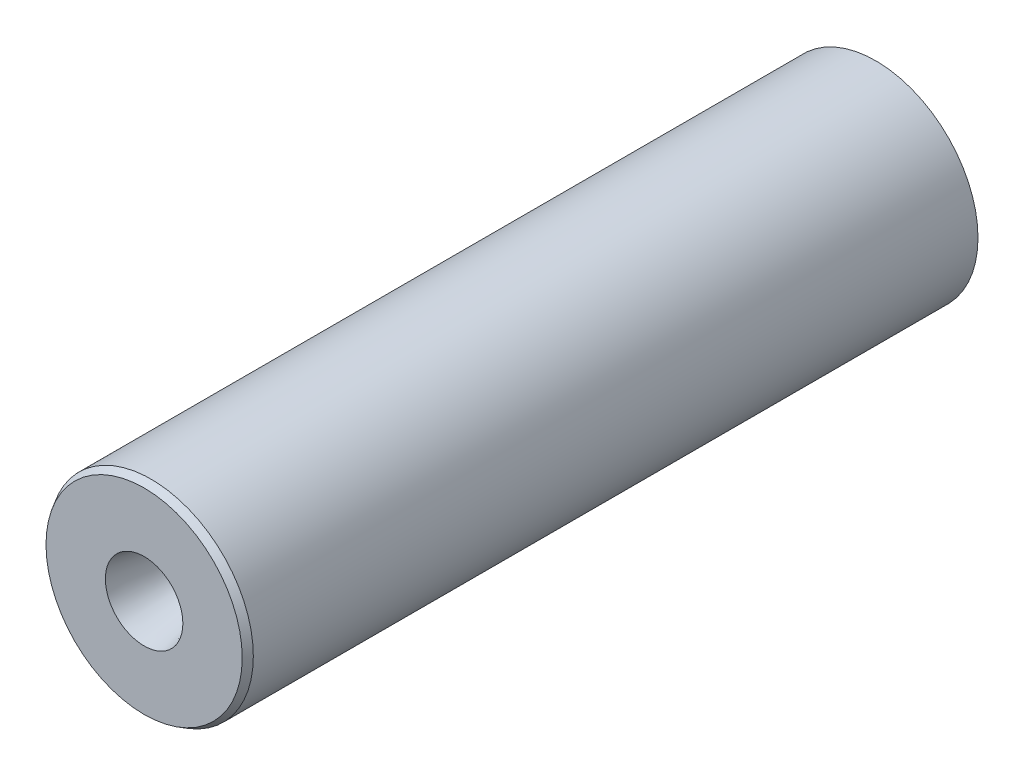
from build123d import *

# Parameters (mm, degrees)
ESQUISSE2_R             = 11
ENL_V_MAT_EXTRU_1_DEPTH = 15
CONG_1_R                = 5
CHANFREIN1_SIZE         = 1
CHANFREIN1_SIZE2        = 0.577350269


with BuildPart() as part:
    # Esquisse1 → Révolution1 (revolve)
    with BuildSketch(Plane(origin=(0, 0, 0), x_dir=(0, 0, -1), z_dir=(1, 0, 0))):
        Polygon((36.918161096, 11), (36.918161096, 9), (51.918161096, 9), (51.918161096, 14.5), (-51.918161096, 14.5), (-51.918161096, 5.5), (-37.804270768, 2.5), (-23.081838904, 11), align=None)
    revolve(axis=Axis((0, 0, 51.918161096), (0, 0, -1)))

    # Esquisse2 → Enlèv. mat.-Extru.1 (cut)
    with BuildSketch(Plane(origin=(0, 0, -51.918161096), x_dir=(-1, 0, 0), z_dir=(0, 0, -1))):
        Circle(ESQUISSE2_R)
    extrude(amount=-ENL_V_MAT_EXTRU_1_DEPTH, mode=Mode.SUBTRACT)

    # Esquisse3 → Enlèvement de matière-Révolution1 (revolve, cut)
    with BuildSketch(Plane(origin=(0, 0, 0), x_dir=(0, 0, -1), z_dir=(1, 0, 0))):
        Polygon((48.918161096, 11), (48.918161096, 12), (46.918161096, 12), (46.918161096, 11), (43.918161096, 11), (43.918161096, 12), (41.918161096, 12), (41.918161096, 11), (38.918161096, 11), (38.918161096, 12), (36.918161096, 12), (36.918161096, 11), (36.918161096, 0), (51.918161096, 0), (51.918161096, 11), align=None)
    revolve(axis=Axis((0, 0, 0), (0, 0, -1)), mode=Mode.SUBTRACT)

    # Congé1
    cong_1_edges = [part.edges().sort_by_distance(p)[0] for p in [
        (0, -11, 23.081838904),
        (0, -2.5, 37.804270768),
    ]]
    fillet(cong_1_edges, radius=CONG_1_R)

    # Chanfrein1
    chanfrein1_edges = [part.edges().sort_by_distance(p)[0] for p in [
        (0, -14.5, 51.918161096),
    ]]
    chanfrein1_side = [part.faces().sort_by_distance(p)[0] for p in [
        (0, -14.5, 0),
    ]]
    chamfer(chanfrein1_edges, length=CHANFREIN1_SIZE, length2=CHANFREIN1_SIZE2, reference=chanfrein1_side[0])


solid = part.part
